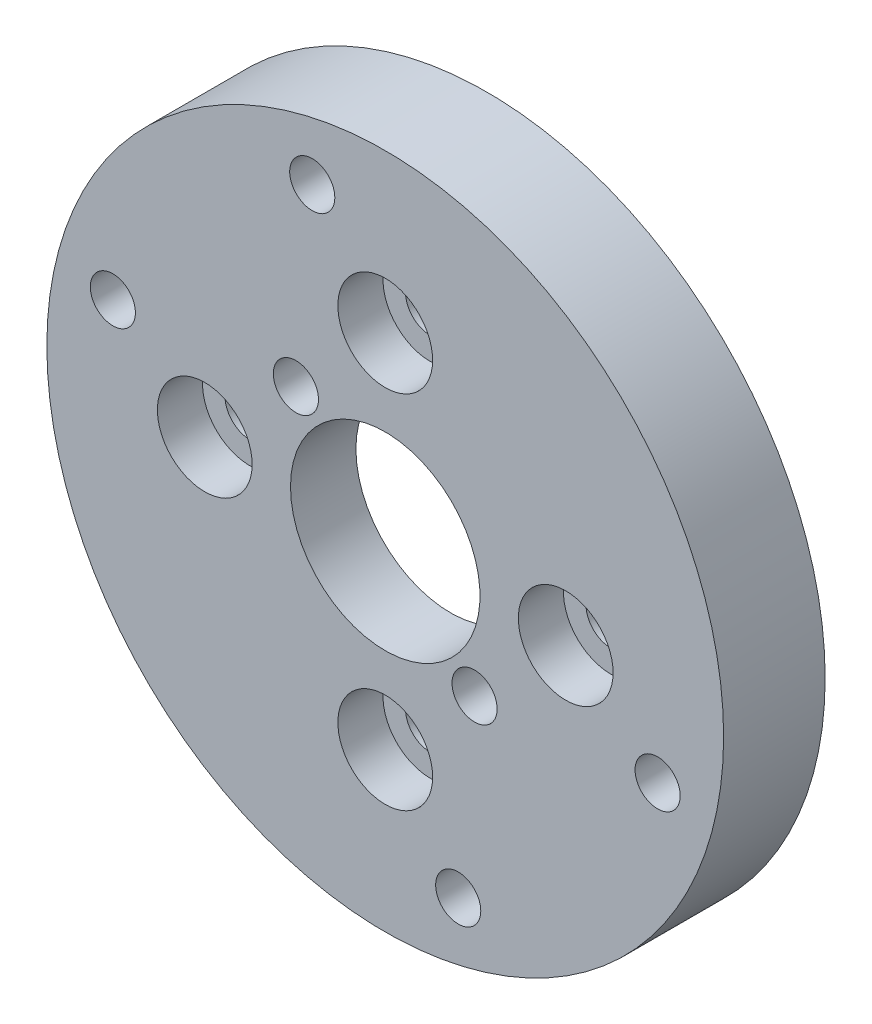
from build123d import *

# Parameters (mm, degrees)
SKETCH_1_R          = 15
SKETCH_1_R_2        = 2.3
SKETCH_1_R_3        = 1.1
SKETCH_1_R_4        = 1
EXTRUDE_1_DEPTH     = 4.5
SKETCH_2_R          = 2.1
CUT_EXTRUDE_1_DEPTH = 2
SKETCH_10_R         = 10
CUT_EXTRUDE_7_DEPTH = 1.6
SKETCH_9_R          = 4.2
CUT_EXTRUDE_5_DEPTH = 3.9
SKETCH_6_R          = 1
CUT_EXTRUDE_6_DEPTH = 2


with BuildPart() as part:
    # 스케치1 → 보스-돌출1 (new body)
    with BuildSketch(Plane.XY):
        Circle(SKETCH_1_R)
        Circle(SKETCH_1_R_2, mode=Mode.SUBTRACT)
        with Locations((0, 8)):
            Circle(SKETCH_1_R_3, mode=Mode.SUBTRACT)
        with Locations((8, 0)):
            Circle(SKETCH_1_R_3, mode=Mode.SUBTRACT)
        with Locations((0, -8)):
            Circle(SKETCH_1_R_3, mode=Mode.SUBTRACT)
        with Locations((-8, 0)):
            Circle(SKETCH_1_R_3, mode=Mode.SUBTRACT)
        with Locations((-3.235238064, 12.074072829)):
            Circle(SKETCH_1_R_4, mode=Mode.SUBTRACT)
        with Locations((12.074072829, -3.235238064)):
            Circle(SKETCH_1_R_4, mode=Mode.SUBTRACT)
        with Locations((3.235238064, -12.074072829)):
            Circle(SKETCH_1_R_4, mode=Mode.SUBTRACT)
        with Locations((-12.074072829, 3.235238064)):
            Circle(SKETCH_1_R_4, mode=Mode.SUBTRACT)
    extrude(amount=EXTRUDE_1_DEPTH)

    # 스케치2 → 컷-돌출1 (cut)
    with BuildSketch(Plane.XY.offset(4.5)):
        with Locations((0, 8)):
            Circle(SKETCH_2_R)
        with Locations((8, 0)):
            Circle(SKETCH_2_R)
        with Locations((0, -8)):
            Circle(SKETCH_2_R)
        with Locations((-8, 0)):
            Circle(SKETCH_2_R)
    extrude(amount=-CUT_EXTRUDE_1_DEPTH, mode=Mode.SUBTRACT)

    # 스케치10 → 컷-돌출7 (cut)
    with BuildSketch(Plane(origin=(0, 0, 0), x_dir=(-1, 0, 0), z_dir=(0, 0, -1))):
        Circle(SKETCH_10_R)
    extrude(amount=-CUT_EXTRUDE_7_DEPTH, mode=Mode.SUBTRACT)

    # 스케치9 → 컷-돌출5 (cut, through all)
    with BuildSketch(Plane(origin=(0, 0, 1.6), x_dir=(-1, 0, 0), z_dir=(0, 0, -1))):
        Circle(SKETCH_9_R)
    extrude(amount=-CUT_EXTRUDE_5_DEPTH, mode=Mode.SUBTRACT)

    # 스케치6 → 컷-돌출6 (cut)
    with BuildSketch(Plane.XY.offset(4.5)):
        with Locations((-3.959797975, 3.959797975)):
            Circle(SKETCH_6_R)
        with Locations((3.959797975, -3.959797975)):
            Circle(SKETCH_6_R)
    extrude(amount=-CUT_EXTRUDE_6_DEPTH, mode=Mode.SUBTRACT)


solid = part.part
